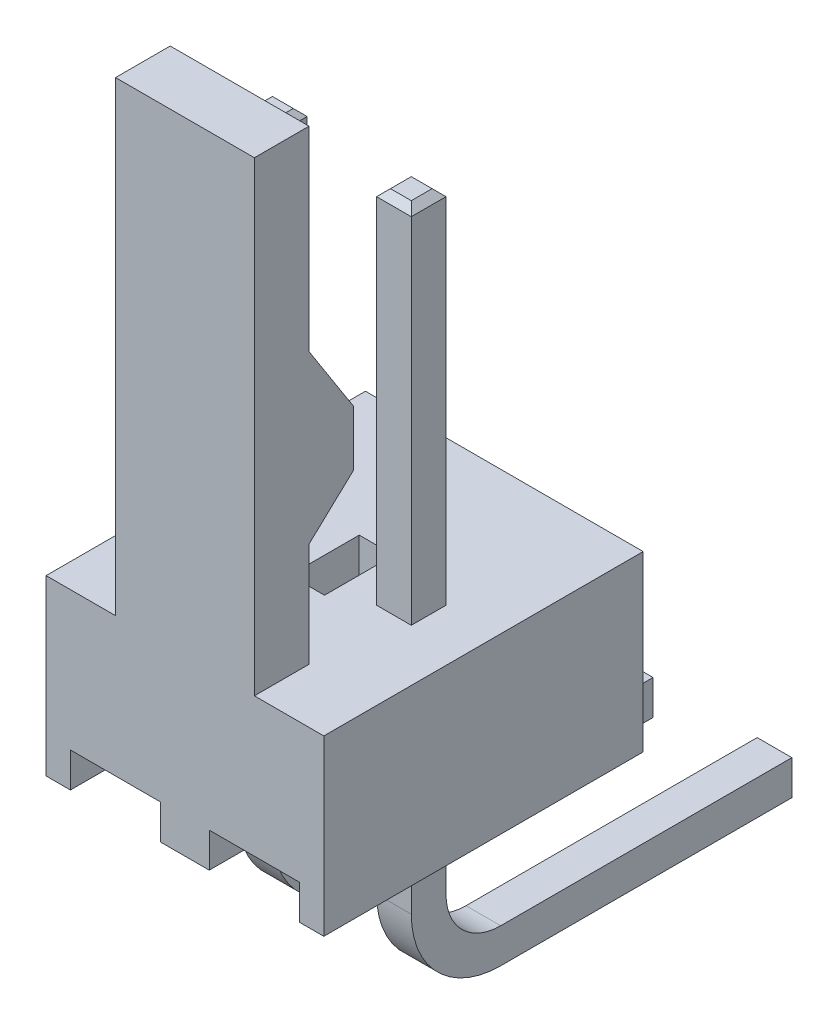
from build123d import *

# Parameters (mm, degrees)
SKETCH68_W           = 7.0893
SKETCH68_H           = 3.6725
BOSS_EXTRUDE17_DEPTH = 0.635
SKETCH69_W           = 6.4543
SKETCH69_H           = 3.0375
CUT_EXTRUDE12_DEPTH  = 1.635
CHAMFER15_SIZE       = 0.127
FILLET17_R           = 1
FILLET18_R           = 1.635
SKETCH74_W           = 7.0893
SKETCH74_H           = 3.6725
BOSS_EXTRUDE18_DEPTH = 0.635
SKETCH75_W           = 6.4543
SKETCH75_H           = 3.0375
CUT_EXTRUDE13_DEPTH  = 4.175
CHAMFER16_SIZE       = 0.127
FILLET19_R           = 1
FILLET20_R           = 1.635
BOSS_EXTRUDE19_DEPTH = 0.635
CHAMFER17_SIZE       = 0.127
BOSS_EXTRUDE20_DEPTH = 0.635
CHAMFER18_SIZE       = 0.127
SKETCH95_W           = 3.81
SKETCH95_H           = 5.842
BOSS_EXTRUDE21_DEPTH = 3.175
BOSS_EXTRUDE22_DEPTH = 2.54
SKETCH104_W          = 5.842
SKETCH104_H          = 3.175
BOSS_EXTRUDE23_DEPTH = 1.27
SKETCH105_W          = 1.651
SKETCH105_H          = 0.635
CUT_EXTRUDE14_DEPTH  = 10.642
SKETCH106_W          = 1.651
SKETCH106_H          = 0.635
CUT_EXTRUDE15_DEPTH  = 10.642
SKETCH107_W          = 0.635
SKETCH107_H          = 1.27
CUT_EXTRUDE16_DEPTH  = 1.27
CHAMFER19_SIZE       = 0.55706549
CHAMFER19_SIZE2      = 0.753913762


with BuildPart() as part:
    # Sketch68 → Boss-Extrude17 (new body)
    with BuildSketch(Plane(origin=(1.5875, 0, 0), x_dir=(0, 0, -1), z_dir=(1, 0, 0))):
        with Locations((0.25535, 1.518750008)):
            Rectangle(SKETCH68_W, SKETCH68_H)
    extrude(amount=-BOSS_EXTRUDE17_DEPTH)

    # Sketch69 → Cut-Extrude12 (cut, through all)
    with BuildSketch(Plane.ZY.offset(-0.9525)):
        with Locations((-0.57285, 1.836250008)):
            Rectangle(SKETCH69_W, SKETCH69_H)
    extrude(amount=-CUT_EXTRUDE12_DEPTH, mode=Mode.SUBTRACT)

    # Chamfer15
    chamfer15_edges = [part.edges().sort_by_distance(p)[0] for p in [
        (1.27, 0.317500008, -3.8),
        (1.5875, 8e-09, -3.8),
        (1.27, -0.317499992, -3.8),
        (0.9525, 8e-09, -3.8),
    ]]
    chamfer(chamfer15_edges, length=CHAMFER15_SIZE)

    # Fillet17
    fillet17_edges = [part.edges().sort_by_distance(p)[0] for p in [
        (1.27, 0.317500008, 2.6543),
    ]]
    fillet(fillet17_edges, radius=FILLET17_R)

    # Fillet18
    fillet18_edges = [part.edges().sort_by_distance(p)[0] for p in [
        (1.27, -0.317499992, 3.2893),
    ]]
    fillet(fillet18_edges, radius=FILLET18_R)


with BuildPart() as body_2:
    # Sketch74 → Boss-Extrude18 (new body)
    with BuildSketch(Plane(origin=(-0.9525, 0, 0), x_dir=(0, 0, -1), z_dir=(1, 0, 0))):
        with Locations((0.25535, 1.518750008)):
            Rectangle(SKETCH74_W, SKETCH74_H)
    extrude(amount=-BOSS_EXTRUDE18_DEPTH)

    # Sketch75 → Cut-Extrude13 (cut, through all)
    with BuildSketch(Plane.ZY.offset(1.5875)):
        with Locations((-0.57285, 1.836250008)):
            Rectangle(SKETCH75_W, SKETCH75_H)
    extrude(amount=-CUT_EXTRUDE13_DEPTH, mode=Mode.SUBTRACT)

    # Chamfer16
    chamfer16_edges = [body_2.edges().sort_by_distance(p)[0] for p in [
        (-1.27, 0.317500008, -3.8),
        (-0.9525, 8e-09, -3.8),
        (-1.27, -0.317499992, -3.8),
        (-1.5875, 8e-09, -3.8),
    ]]
    chamfer(chamfer16_edges, length=CHAMFER16_SIZE)

    # Fillet19
    fillet19_edges = [body_2.edges().sort_by_distance(p)[0] for p in [
        (-1.27, 0.317500008, 2.6543),
    ]]
    fillet(fillet19_edges, radius=FILLET19_R)

    # Fillet20
    fillet20_edges = [body_2.edges().sort_by_distance(p)[0] for p in [
        (-1.27, -0.317499992, 3.2893),
    ]]
    fillet(fillet20_edges, radius=FILLET20_R)


with BuildPart() as body_3:
    # Sketch81 → Boss-Extrude19 (new body)
    with BuildSketch(Plane(origin=(0, 0, 2.6543), x_dir=(-1, 0, 0), z_dir=(0, 0, -1))):
        Polygon((-0.9525, 5.895000008), (-0.9525, 12.368000008), (-0.9525, 12.495000008), (-1.5875, 12.495000008), (-1.5875, 12.368000008), (-1.5875, 5.895000008), align=None)
    extrude(amount=-BOSS_EXTRUDE19_DEPTH)

    # Chamfer17
    chamfer17_edges = [body_3.edges().sort_by_distance(p)[0] for p in [
        (1.5875, 12.495000008, 2.9718),
        (0.9525, 12.495000008, 2.9718),
        (1.27, 12.495000008, 3.2893),
        (1.27, 12.495000008, 2.6543),
    ]]
    chamfer(chamfer17_edges, length=CHAMFER17_SIZE)


with BuildPart() as body_4:
    # Sketch88 → Boss-Extrude20 (new body)
    with BuildSketch(Plane(origin=(0, 0, 2.6543), x_dir=(-1, 0, 0), z_dir=(0, 0, -1))):
        Polygon((1.5875, 5.895000008), (1.5875, 12.368000008), (1.5875, 12.495000008), (0.9525, 12.495000008), (0.9525, 12.368000008), (0.9525, 5.895000008), align=None)
    extrude(amount=-BOSS_EXTRUDE20_DEPTH)

    # Chamfer18
    chamfer18_edges = [body_4.edges().sort_by_distance(p)[0] for p in [
        (-0.9525, 12.495000008, 2.9718),
        (-1.5875, 12.495000008, 2.9718),
        (-1.27, 12.495000008, 3.2893),
        (-1.27, 12.495000008, 2.6543),
    ]]
    chamfer(chamfer18_edges, length=CHAMFER18_SIZE)


with BuildPart() as body_5:
    # Sketch95 → Boss-Extrude21 (new body)
    with BuildSketch(Plane(origin=(0, 2.720000008, 0), x_dir=(-1, 0, 0), z_dir=(0, -1, 0))):
        with Locations((-0.635, -2.921)):
            Rectangle(SKETCH95_W, SKETCH95_H)
    extrude(amount=-BOSS_EXTRUDE21_DEPTH)

    # Sketch103 → Boss-Extrude22 (add)
    with BuildSketch(Plane.ZY.offset(1.27)):
        Polygon((4.842, 7.800000008), (4.842, 5.895000008), (5.842, 5.895000008), (5.842, 14.420000008), (4.842, 14.420000008), (4.842, 10.848000008), (3.6228, 8.943000008), align=None)
    extrude(amount=-BOSS_EXTRUDE22_DEPTH)

    # Sketch104 → Boss-Extrude23 (add)
    with BuildSketch(Plane.ZY.offset(1.27)):
        with Locations((2.921, 4.307500008)):
            Rectangle(SKETCH104_W, SKETCH104_H)
    extrude(amount=BOSS_EXTRUDE23_DEPTH)

    # Sketch105 → Cut-Extrude14 (cut, through all)
    with BuildSketch(Plane.XY.offset(5.842)):
        with Locations((1.27, 3.037500008)):
            Rectangle(SKETCH105_W, SKETCH105_H)
    extrude(amount=-CUT_EXTRUDE14_DEPTH, mode=Mode.SUBTRACT)

    # Sketch106 → Cut-Extrude15 (cut, through all)
    with BuildSketch(Plane.XY.offset(5.842)):
        with Locations((-1.27, 3.037500008)):
            Rectangle(SKETCH106_W, SKETCH106_H)
    extrude(amount=-CUT_EXTRUDE15_DEPTH, mode=Mode.SUBTRACT)

    # Sketch107 → Cut-Extrude16 (cut)
    with BuildSketch(Plane(origin=(0, 5.895000008, 0), x_dir=(-1, 0, 0), z_dir=(0, 1, 0))):
        with Locations((0, 2.9718)):
            Rectangle(SKETCH107_W, SKETCH107_H)
    extrude(amount=-CUT_EXTRUDE16_DEPTH, mode=Mode.SUBTRACT)

    # Chamfer19
    chamfer19_edges = [body_5.edges().sort_by_distance(p)[0] for p in [
        (0, 8.943000008, 3.6228),
    ]]
    chamfer19_side = [body_5.faces().sort_by_distance(p)[0] for p in [
        (0, 8.371500008, 4.2324),
    ]]
    chamfer(chamfer19_edges, length=CHAMFER19_SIZE, length2=CHAMFER19_SIZE2, reference=chamfer19_side[0])


solid = Compound([part.part, body_2.part, body_3.part, body_4.part, body_5.part])
